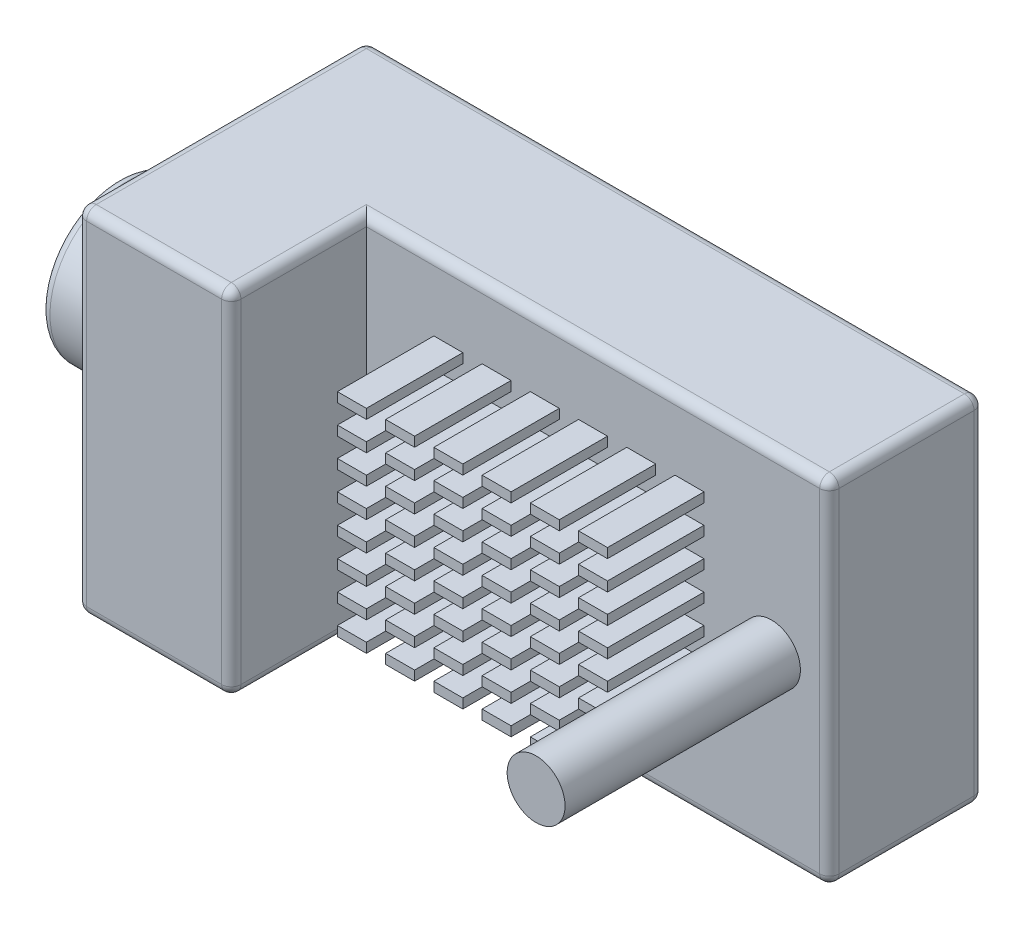
from build123d import *

# Parameters (mm, degrees)
SKETCH_1_W          = 32
SKETCH_1_H          = 18.3
EXTRUDE_1_DEPTH     = 4
SKETCH_2_W          = 8
SKETCH_2_H          = 18.3
EXTRUDE_2_DEPTH     = 7
SKETCH_4_R          = 2.5
EXTRUDE_3_DEPTH     = 2
SKETCH_5_R          = 4
EXTRUDE_4_DEPTH     = 3.4
SKETCH_6_W          = 15
SKETCH_6_H          = 12
EXTRUDE_5_DEPTH     = 5
SKETCH_7_W          = 15
SKETCH_7_H          = 12
SKETCH_7_W_2        = 1.5
SKETCH_7_H_2        = 0.5
CUT_EXTRUDE_1_DEPTH = 5
SKETCH_8_R          = 1.5
EXTRUDE_6_DEPTH     = 12.2
FILLET_1_R          = 0.5
FILLET_2_R          = 0.5


with BuildPart() as part:
    # 草圖1 → 填料-伸長1 (new body, symmetric)
    with BuildSketch(Plane.XY):
        Rectangle(SKETCH_1_W, SKETCH_1_H)
    extrude(amount=EXTRUDE_1_DEPTH, both=True)

    # 草圖2 → 填料-伸長2 (add)
    with BuildSketch(Plane.XY.offset(4)):
        with Locations((-12, 0)):
            Rectangle(SKETCH_2_W, SKETCH_2_H)
    extrude(amount=EXTRUDE_2_DEPTH)

    # 草圖4 → 填料-伸長3 (add)
    with BuildSketch(Plane.ZY.offset(16)):
        with Locations((3.5, 0)):
            Circle(SKETCH_4_R)
    extrude(amount=EXTRUDE_3_DEPTH)

    # 草圖5 → 填料-伸長4 (add)
    with BuildSketch(Plane.ZY.offset(18)):
        with Locations((3.5, 0)):
            Circle(SKETCH_5_R)
    extrude(amount=EXTRUDE_4_DEPTH)

    # 草圖6 → 填料-伸長5 (add)
    with BuildSketch(Plane.XY.offset(4)):
        with Locations((2.5, 0)):
            Rectangle(SKETCH_6_W, SKETCH_6_H)
    extrude(amount=EXTRUDE_5_DEPTH)

    # 草圖7 → 除料-伸長1 (cut)
    with BuildSketch(Plane.XY.offset(9)):
        with Locations((2.5, 0)):
            Rectangle(SKETCH_7_W, SKETCH_7_H)
        with Locations((-1.25, 5.25)):
            Rectangle(SKETCH_7_W_2, SKETCH_7_H_2, mode=Mode.SUBTRACT)
        with Locations((-3.75, 5.25)):
            Rectangle(SKETCH_7_W_2, SKETCH_7_H_2, mode=Mode.SUBTRACT)
        with Locations((1.25, 5.25)):
            Rectangle(SKETCH_7_W_2, SKETCH_7_H_2, mode=Mode.SUBTRACT)
        with Locations((3.75, 5.25)):
            Rectangle(SKETCH_7_W_2, SKETCH_7_H_2, mode=Mode.SUBTRACT)
        with Locations((6.25, 5.25)):
            Rectangle(SKETCH_7_W_2, SKETCH_7_H_2, mode=Mode.SUBTRACT)
        with Locations((8.75, 5.25)):
            Rectangle(SKETCH_7_W_2, SKETCH_7_H_2, mode=Mode.SUBTRACT)
        with Locations((-3.75, 3.75)):
            Rectangle(SKETCH_7_W_2, SKETCH_7_H_2, mode=Mode.SUBTRACT)
        with Locations((-1.25, 3.75)):
            Rectangle(SKETCH_7_W_2, SKETCH_7_H_2, mode=Mode.SUBTRACT)
        with Locations((1.25, 3.75)):
            Rectangle(SKETCH_7_W_2, SKETCH_7_H_2, mode=Mode.SUBTRACT)
        with Locations((3.75, 3.75)):
            Rectangle(SKETCH_7_W_2, SKETCH_7_H_2, mode=Mode.SUBTRACT)
        with Locations((6.25, 3.75)):
            Rectangle(SKETCH_7_W_2, SKETCH_7_H_2, mode=Mode.SUBTRACT)
        with Locations((8.75, 3.75)):
            Rectangle(SKETCH_7_W_2, SKETCH_7_H_2, mode=Mode.SUBTRACT)
        with Locations((-3.75, 2.25)):
            Rectangle(SKETCH_7_W_2, SKETCH_7_H_2, mode=Mode.SUBTRACT)
        with Locations((-1.25, 2.25)):
            Rectangle(SKETCH_7_W_2, SKETCH_7_H_2, mode=Mode.SUBTRACT)
        with Locations((1.25, 2.25)):
            Rectangle(SKETCH_7_W_2, SKETCH_7_H_2, mode=Mode.SUBTRACT)
        with Locations((3.75, 2.25)):
            Rectangle(SKETCH_7_W_2, SKETCH_7_H_2, mode=Mode.SUBTRACT)
        with Locations((6.25, 2.25)):
            Rectangle(SKETCH_7_W_2, SKETCH_7_H_2, mode=Mode.SUBTRACT)
        with Locations((8.75, 2.25)):
            Rectangle(SKETCH_7_W_2, SKETCH_7_H_2, mode=Mode.SUBTRACT)
        with Locations((-3.75, 0.75)):
            Rectangle(SKETCH_7_W_2, SKETCH_7_H_2, mode=Mode.SUBTRACT)
        with Locations((-1.25, 0.75)):
            Rectangle(SKETCH_7_W_2, SKETCH_7_H_2, mode=Mode.SUBTRACT)
        with Locations((1.25, 0.75)):
            Rectangle(SKETCH_7_W_2, SKETCH_7_H_2, mode=Mode.SUBTRACT)
        with Locations((3.75, 0.75)):
            Rectangle(SKETCH_7_W_2, SKETCH_7_H_2, mode=Mode.SUBTRACT)
        with Locations((6.25, 0.75)):
            Rectangle(SKETCH_7_W_2, SKETCH_7_H_2, mode=Mode.SUBTRACT)
        with Locations((8.75, 0.75)):
            Rectangle(SKETCH_7_W_2, SKETCH_7_H_2, mode=Mode.SUBTRACT)
        with Locations((-3.75, -0.75)):
            Rectangle(SKETCH_7_W_2, SKETCH_7_H_2, mode=Mode.SUBTRACT)
        with Locations((-1.25, -0.75)):
            Rectangle(SKETCH_7_W_2, SKETCH_7_H_2, mode=Mode.SUBTRACT)
        with Locations((1.25, -0.75)):
            Rectangle(SKETCH_7_W_2, SKETCH_7_H_2, mode=Mode.SUBTRACT)
        with Locations((3.75, -0.75)):
            Rectangle(SKETCH_7_W_2, SKETCH_7_H_2, mode=Mode.SUBTRACT)
        with Locations((6.25, -0.75)):
            Rectangle(SKETCH_7_W_2, SKETCH_7_H_2, mode=Mode.SUBTRACT)
        with Locations((8.75, -0.75)):
            Rectangle(SKETCH_7_W_2, SKETCH_7_H_2, mode=Mode.SUBTRACT)
        with Locations((-3.75, -2.25)):
            Rectangle(SKETCH_7_W_2, SKETCH_7_H_2, mode=Mode.SUBTRACT)
        with Locations((-1.25, -2.25)):
            Rectangle(SKETCH_7_W_2, SKETCH_7_H_2, mode=Mode.SUBTRACT)
        with Locations((1.25, -2.25)):
            Rectangle(SKETCH_7_W_2, SKETCH_7_H_2, mode=Mode.SUBTRACT)
        with Locations((3.75, -2.25)):
            Rectangle(SKETCH_7_W_2, SKETCH_7_H_2, mode=Mode.SUBTRACT)
        with Locations((6.25, -2.25)):
            Rectangle(SKETCH_7_W_2, SKETCH_7_H_2, mode=Mode.SUBTRACT)
        with Locations((8.75, -2.25)):
            Rectangle(SKETCH_7_W_2, SKETCH_7_H_2, mode=Mode.SUBTRACT)
        with Locations((-3.75, -3.75)):
            Rectangle(SKETCH_7_W_2, SKETCH_7_H_2, mode=Mode.SUBTRACT)
        with Locations((-1.25, -3.75)):
            Rectangle(SKETCH_7_W_2, SKETCH_7_H_2, mode=Mode.SUBTRACT)
        with Locations((1.25, -3.75)):
            Rectangle(SKETCH_7_W_2, SKETCH_7_H_2, mode=Mode.SUBTRACT)
        with Locations((3.75, -3.75)):
            Rectangle(SKETCH_7_W_2, SKETCH_7_H_2, mode=Mode.SUBTRACT)
        with Locations((6.25, -3.75)):
            Rectangle(SKETCH_7_W_2, SKETCH_7_H_2, mode=Mode.SUBTRACT)
        with Locations((8.75, -3.75)):
            Rectangle(SKETCH_7_W_2, SKETCH_7_H_2, mode=Mode.SUBTRACT)
        with Locations((-3.75, -5.25)):
            Rectangle(SKETCH_7_W_2, SKETCH_7_H_2, mode=Mode.SUBTRACT)
        with Locations((-1.25, -5.25)):
            Rectangle(SKETCH_7_W_2, SKETCH_7_H_2, mode=Mode.SUBTRACT)
        with Locations((1.25, -5.25)):
            Rectangle(SKETCH_7_W_2, SKETCH_7_H_2, mode=Mode.SUBTRACT)
        with Locations((3.75, -5.25)):
            Rectangle(SKETCH_7_W_2, SKETCH_7_H_2, mode=Mode.SUBTRACT)
        with Locations((6.25, -5.25)):
            Rectangle(SKETCH_7_W_2, SKETCH_7_H_2, mode=Mode.SUBTRACT)
        with Locations((8.75, -5.25)):
            Rectangle(SKETCH_7_W_2, SKETCH_7_H_2, mode=Mode.SUBTRACT)
    extrude(amount=-CUT_EXTRUDE_1_DEPTH, mode=Mode.SUBTRACT)

    # 草圖8 → 填料-伸長6 (add)
    with BuildSketch(Plane.XY.offset(4)):
        with Locations((13, 0)):
            Circle(SKETCH_8_R)
    extrude(amount=EXTRUDE_6_DEPTH)

    # 圓角1
    fillet_1_edges = [part.edges().sort_by_distance(p)[0] for p in [
        (4, -9.15, 4),
        (-8, -9.15, 7.5),
        (-8, 9.15, 7.5),
        (-16, 0, 11),
        (-12, -9.15, 11),
        (-8, 0, 11),
        (-12, 9.15, 11),
        (-16, 0, 1),
        (16, 0, 4),
        (0, -9.15, -4),
        (-16, 0, -4),
        (0, 9.15, -4),
        (16, 0, -4),
        (4, 9.15, 4),
        (16, -9.15, 0),
        (-16, -9.15, 3.5),
        (-16, 9.15, 3.5),
        (16, 9.15, 0),
    ]]
    fillet(fillet_1_edges, radius=FILLET_1_R)

    # 圓角2
    fillet_2_edges = [part.edges().sort_by_distance(p)[0] for p in [
        (-18, 0, 1),
        (-18, 0, -0.5),
        (-21.4, 0, -0.5),
    ]]
    fillet(fillet_2_edges, radius=FILLET_2_R)


solid = part.part
